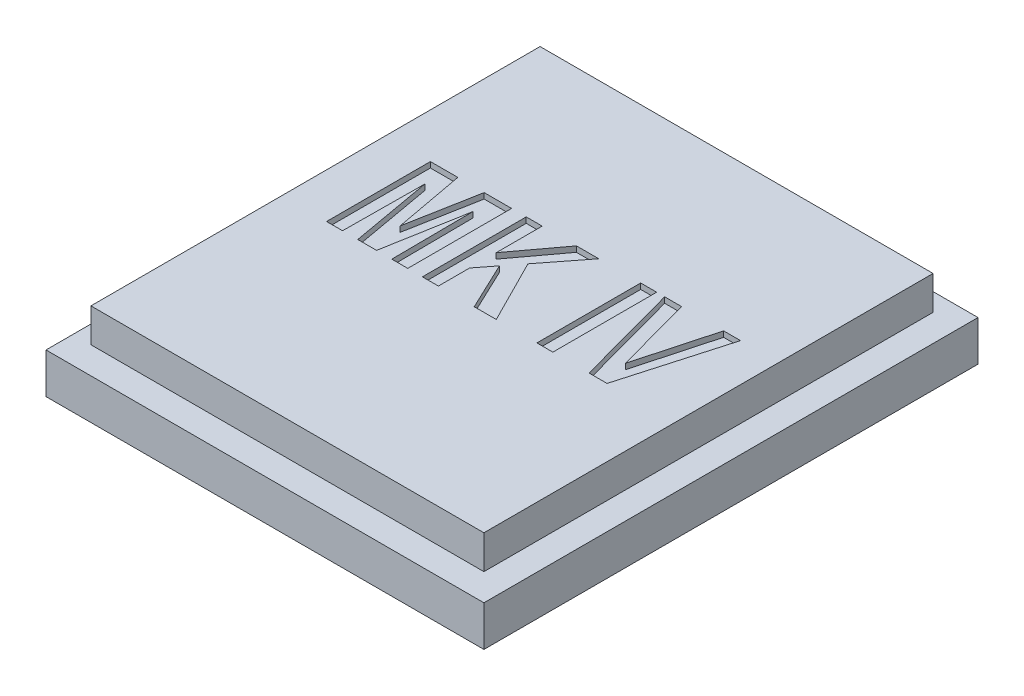
from build123d import *

# Parameters (mm, degrees)
SKETCH1_W           = 27.8
SKETCH1_H           = 29.8
BOSS_EXTRUDE1_DEPTH = 4
SKETCH2_W           = 35
SKETCH2_H           = 40
BOSS_EXTRUDE2_DEPTH = 3
CHAMFER1_SIZE       = 0.4
CHAMFER1_SIZE2      = 1.098990968
SKETCH4_W           = 39
SKETCH4_H           = 44
SKETCH4_W_2         = 31
SKETCH4_H_2         = 37
BOSS_EXTRUDE4_DEPTH = 3.6
SKETCH3_W           = 1.422453426
SKETCH3_H           = 9.245947266
CUT_EXTRUDE1_DEPTH  = 0.5


with BuildPart() as part:
    # Sketch1 → Boss-Extrude1 (new body)
    with BuildSketch(Plane(origin=(0, 0, 0), x_dir=(1, 0, 0), z_dir=(0, 1, 0))):
        Rectangle(SKETCH1_W, SKETCH1_H)
    extrude(amount=BOSS_EXTRUDE1_DEPTH)

    # Sketch2 → Boss-Extrude2 (add)
    with BuildSketch(Plane(origin=(0, 4, 0), x_dir=(1, 0, 0), z_dir=(0, 1, 0))):
        with Locations((-1.1, 3.1)):
            Rectangle(SKETCH2_W, SKETCH2_H)
    extrude(amount=BOSS_EXTRUDE2_DEPTH)

    # Chamfer1
    chamfer1_edges = [part.edges().sort_by_distance(p)[0] for p in [
        (0, 0, -14.9),
        (13.9, 0, 0),
        (0, 0, 14.9),
        (-13.9, 0, 0),
    ]]
    chamfer1_side = [part.faces().sort_by_distance(p)[0] for p in [
        (0, 0, 0),
    ]]
    chamfer(chamfer1_edges, length=CHAMFER1_SIZE, length2=CHAMFER1_SIZE2, reference=chamfer1_side[0])

    # Sketch3 → Cut-Extrude1 (cut)
    with BuildSketch(Plane(origin=(0, 7, 0), x_dir=(1, 0, 0), z_dir=(0, 1, 0))):
        Polygon((-14.613307542, 0.1), (-14.613307542, 9.345947266), (-12.17031787, 9.345947266), (-10.997905086, 3.039366649), (-9.825492301, 9.345947266), (-7.382502629, 9.345947266), (-7.382502629, 0.1), (-8.804956055, 0.1), (-8.864224947, 7.378960888), (-10.160731976, 0.1), (-11.835078195, 0.1), (-13.131585224, 7.378960888), (-13.190854117, 0.1), align=None)
        Polygon((-6.078586989, 0.1), (-6.078586989, 9.345947266), (-4.656133564, 9.345947266), (-4.656133564, 5.247132903), (-1.609342047, 9.345947266), (0.381722318, 9.345947266), (-2.381689805, 5.802778772), (0.500260104, 0.1), (-1.464874121, 0.1), (-3.494833697, 4.376621041), (-4.656133564, 2.887490111), (-4.656133564, 0.1), align=None)
        with Locations((4.826889273, 4.722973633)):
            Rectangle(SKETCH3_W, SKETCH3_H)
        Polygon((8.764566333, 0.1), (6.249342698, 9.345947266), (7.756995157, 9.345947266), (9.627669584, 2.470755709), (11.500196163, 9.345947266), (13.005996469, 9.345947266), (10.364826437, 0.1), align=None)
    extrude(amount=-CUT_EXTRUDE1_DEPTH, mode=Mode.SUBTRACT)


with BuildPart() as body_2:
    # Sketch4 → Boss-Extrude4 (new body)
    with BuildSketch(Plane.XZ):
        with Locations((-1.1, -3.1)):
            Rectangle(SKETCH4_W, SKETCH4_H)
        with Locations((-1.1, -3.1)):
            Rectangle(SKETCH4_W_2, SKETCH4_H_2, mode=Mode.SUBTRACT)
    extrude(amount=-BOSS_EXTRUDE4_DEPTH)


solid = Compound([part.part, body_2.part])
